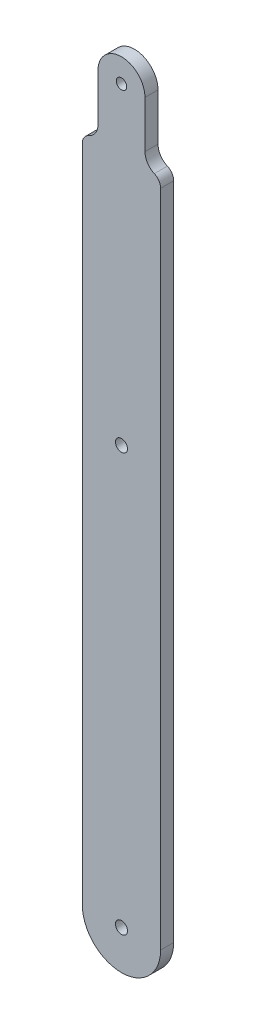
from build123d import *

# Parameters (mm, degrees)
SKETCH1_R           = 1.4605
SKETCH1_R_2         = 1.27
BOSS_EXTRUDE1_DEPTH = 3.175
SKETCH3_R           = 1.4605
CUT_EXTRUDE2_DEPTH  = 3.175


with BuildPart() as part:
    # Sketch1 → Boss-Extrude1 (new body)
    with BuildSketch(Plane.XY):
        with BuildLine():
            Line((-19.353012887, 135.150128867), (-19.353012887, -25.400000121))
            ThreePointArc((-19.353012887, -25.400000121), (-9.828012887, -34.925000121), (-0.303012887, -25.400000121))
            Line((-0.303012887, -25.400000121), (-0.303012887, 135.150128867))
            ThreePointArc((-0.303012887, 135.150128867), (-0.71789642, 136.541344163), (-1.827012887, 137.47807732))
            ThreePointArc((-1.827012887, 137.47807732), (-3.490687589, 138.883177056), (-4.113012887, 140.97))
            Line((-4.113012887, 140.97), (-4.113012887, 152.4))
            ThreePointArc((-4.113012887, 152.4), (-9.828012887, 158.115), (-15.543012887, 152.4))
            Line((-15.543012887, 152.4), (-15.543012887, 140.97))
            ThreePointArc((-15.543012887, 140.97), (-16.165338186, 138.883177056), (-17.829012887, 137.47807732))
            ThreePointArc((-17.829012887, 137.47807732), (-18.938129355, 136.541344163), (-19.353012887, 135.150128867))
        make_face()
        with Locations((-9.828012887, -25.400000121)):
            Circle(SKETCH1_R, mode=Mode.SUBTRACT)
        with Locations((-9.828012887, 152.4)):
            Circle(SKETCH1_R_2, mode=Mode.SUBTRACT)
    extrude(amount=BOSS_EXTRUDE1_DEPTH)

    # Sketch3 → Cut-Extrude2 (cut)
    with BuildSketch(Plane.XY.offset(3.175)):
        with Locations((-9.828012887, 76.2)):
            Circle(SKETCH3_R)
    extrude(amount=-CUT_EXTRUDE2_DEPTH, mode=Mode.SUBTRACT)


solid = part.part
